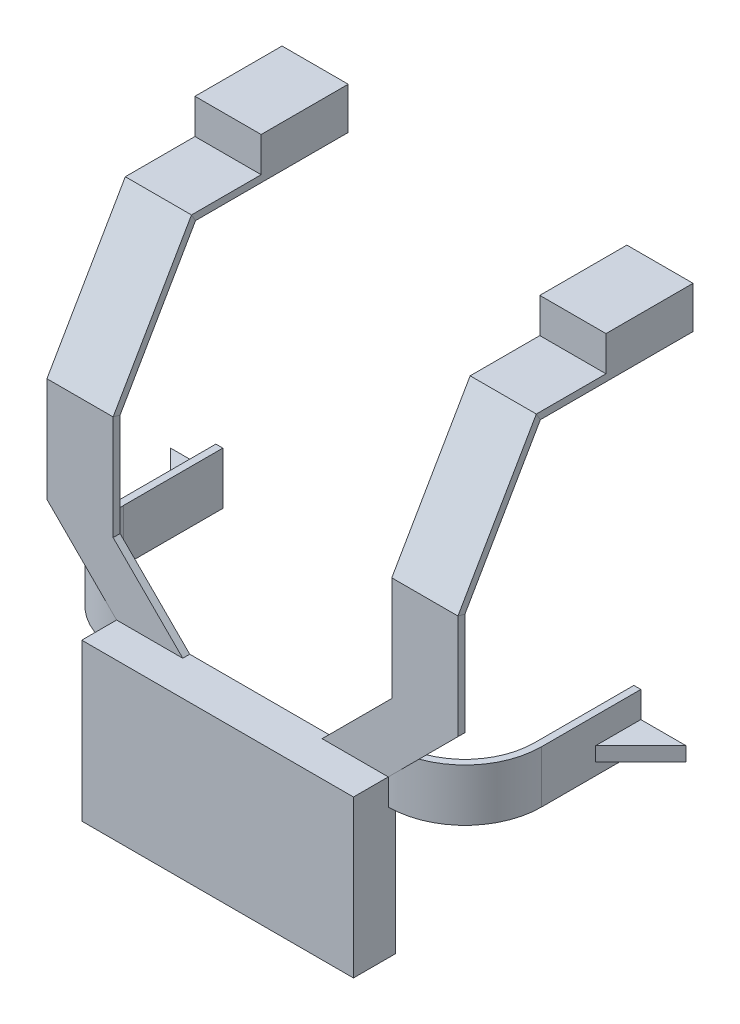
from build123d import *

# Parameters (mm, degrees)
EXTRUDE_1_DEPTH     = 4
SKETCH_11_W         = 156
SKETCH_11_H         = 90
EXTRUDE_2_DEPTH     = 20
SKETCH_12_W         = 38
SKETCH_12_H         = 4
SKETCH_14_W         = 38
SKETCH_14_H         = 50
EXTRUDE_3_DEPTH     = 20
SKETCH_16_W         = 238.183586275
SKETCH_16_H         = 132.295328182
CUT_EXTRUDE_1_DEPTH = 10
SKETCH_17_W         = 40
SKETCH_17_H         = 20
EXTRUDE_4_DEPTH     = 4
SKETCH_21_R         = 6
EXTRUDE_8_DEPTH     = 4
EXTRUDE_11_DEPTH    = 15
EXTRUDE_12_DEPTH    = 8


with BuildPart() as part:
    # 草图1 → 凸台-拉伸1 (new body)
    with BuildSketch(Plane.XY):
        Polygon((-40, 0), (40, 0), (40, -160), (78, -160), (78, 0), (78, 50), (118, 90), (80, 90), (40, 50), (-40, 50), (-80, 90), (-118, 90), (-78, 50), (-78, 0), (-78, -160), (-40, -160), align=None)
    extrude(amount=EXTRUDE_1_DEPTH)

    # 草图11 → 凸台-拉伸2 (add)
    with BuildSketch(Plane.XY.offset(4)):
        with Locations((0, 5)):
            Rectangle(SKETCH_11_W, SKETCH_11_H)
    extrude(amount=EXTRUDE_2_DEPTH)

    # 扫描1: sweep along a path in 草图13
    with BuildLine(Plane(origin=(78, 0, 0), x_dir=(0, 0, -1), z_dir=(1, 0, 0))) as sweep_1_path:
        Line((-4, 90), (-4, 150))
        Line((-4, 150), (41, 227.942286341))
        Line((41, 227.942286341), (131, 227.942286341))
    # 草图12 → 扫描1 (sweep)
    with BuildSketch(Plane(origin=(0, 90, 0), x_dir=(1, 0, 0), z_dir=(0, 1, 0))):
        with Locations((-99, -2)):
            Rectangle(SKETCH_12_W, SKETCH_12_H)
        with Locations((99, -2)):
            Rectangle(SKETCH_12_W, SKETCH_12_H)
    sweep(path=sweep_1_path.line, transition=Transition.RIGHT)

    # 草图14 → 凸台-拉伸3 (add)
    with BuildSketch(Plane(origin=(0, 227.942286341, 0), x_dir=(1, 0, 0), z_dir=(0, 1, 0))):
        with Locations((-99, 106)):
            Rectangle(SKETCH_14_W, SKETCH_14_H)
        with Locations((99, 106)):
            Rectangle(SKETCH_14_W, SKETCH_14_H)
    extrude(amount=EXTRUDE_3_DEPTH)

    # 草图16 → 切除-拉伸1 (cut)
    with BuildSketch(Plane(origin=(0, 0, 0), x_dir=(-1, 0, 0), z_dir=(0, 0, -1))):
        with Locations((8.714033644, -106.147664091)):
            Rectangle(SKETCH_16_W, SKETCH_16_H)
    extrude(amount=-CUT_EXTRUDE_1_DEPTH, mode=Mode.SUBTRACT)

    # 草图17 → 凸台-拉伸4 (add)
    with BuildSketch(Plane.XZ.offset(40)):
        with Locations((0, 10)):
            Rectangle(SKETCH_17_W, SKETCH_17_H)
    extrude(amount=EXTRUDE_4_DEPTH)

    # 草图21 → 凸台-拉伸8 (add)
    with BuildSketch(Plane.XZ.offset(44)):
        with Locations((0, 9.5)):
            Circle(SKETCH_21_R)
    extrude(amount=EXTRUDE_8_DEPTH)

    # 草图28 → 凸台-拉伸11 (add, symmetric)
    with BuildSketch(Plane(origin=(0, 50, 0), x_dir=(1, 0, 0), z_dir=(0, 1, 0))):
        with BuildLine():
            Line((-122, 40), (-122, 97))
            Line((-122, 97), (-118, 97))
            Line((-118, 97), (-118, 40))
            ThreePointArc((-118, 40), (-106.284271247, 11.715728753), (-78, 0))
            Line((-78, 0), (-78, -4))
            ThreePointArc((-78, -4), (-109.112698372, 8.887301628), (-122, 40))
        make_face()
        with BuildLine():
            Line((118, 40), (118, 97))
            Line((118, 97), (122, 97))
            Line((122, 97), (122, 40))
            ThreePointArc((122, 40), (109.112698372, 8.887301628), (78, -4))
            Line((78, -4), (78, 0))
            ThreePointArc((78, 0), (106.284271247, 11.715728753), (118, 40))
        make_face()
    extrude(amount=EXTRUDE_11_DEPTH, both=True)

    # 草图29 → 凸台-拉伸12 (add)
    with BuildSketch(Plane(origin=(0, 50, 0), x_dir=(1, 0, 0), z_dir=(0, 1, 0))):
        Polygon((122, 97), (148, 97), (122, 71), align=None)
        Polygon((-122, 97), (-148, 97), (-122, 71), align=None)
    extrude(amount=-EXTRUDE_12_DEPTH)


solid = part.part
